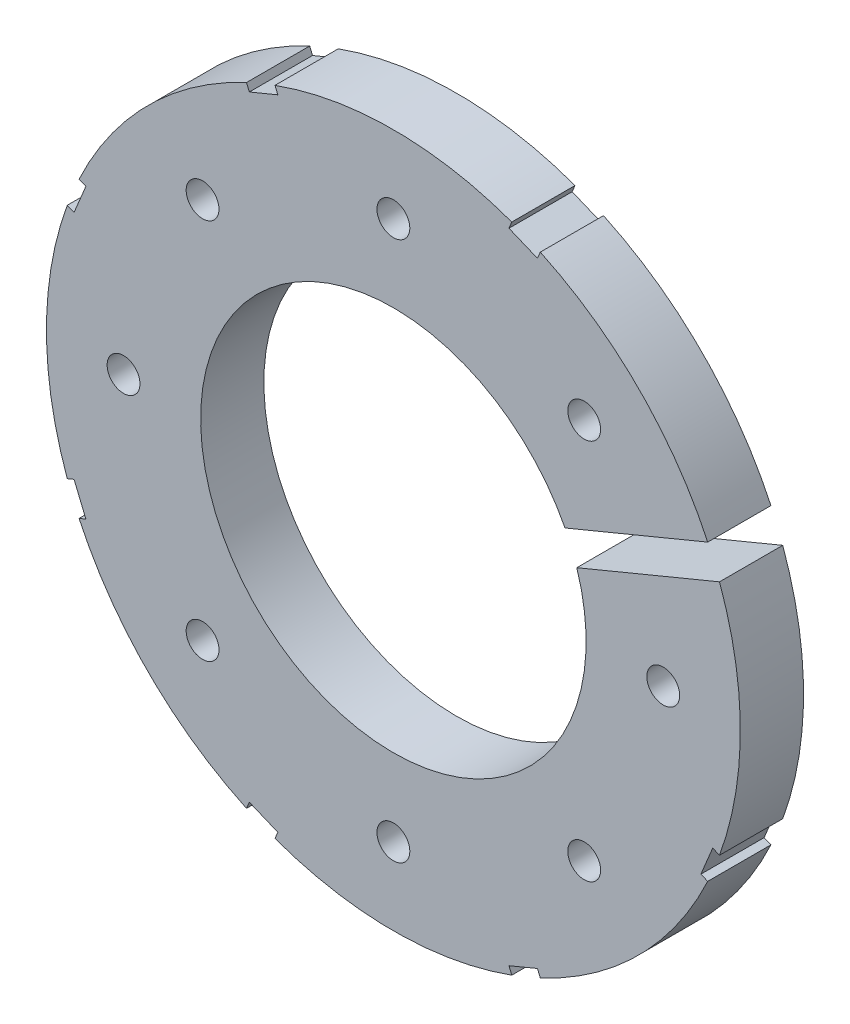
from build123d import *

# Parameters (mm, degrees)
SKETCH4_R             = 28.575
BOSS_EXTRUDE2_DEPTH   = 5.207
SKETCH5_R             = 15.875
CUT_EXTRUDE5_DEPTH    = 6.207
CUT_EXTRUDE11_DEPTH   = 6.207
F_6_32_TAPPED_HOLE1_D = 2.7051


with BuildPart() as part:
    # Sketch4 → Boss-Extrude2 (new body)
    with BuildSketch(Plane.XY):
        Circle(SKETCH4_R)
    extrude(amount=BOSS_EXTRUDE2_DEPTH)

    # Sketch5 → Cut-Extrude5 (cut, through all)
    with BuildSketch(Plane.XY.offset(5.207)):
        Circle(SKETCH5_R)
    extrude(amount=-CUT_EXTRUDE5_DEPTH, mode=Mode.SUBTRACT)

    # Sketch8 → Cut-Extrude11 (cut, through all)
    with BuildSketch(Plane.XY.offset(5.207)):
        Polygon((32.367148217, 14.781549861), (13.593916116, 7.005422516), (14.565932035, 4.658768503), (33.339164135, 12.434895849), align=None)
        Polygon((12.351510066, 26.500513186), (10.004856053, 27.472529104), (9.518848094, 26.299202097), (11.865502107, 25.327186179), align=None)
        Polygon((-10.004856053, 27.472529104), (-12.351510066, 26.500513186), (-11.865502107, 25.327186179), (-9.518848094, 26.299202097), align=None)
        Polygon((-26.500513186, 12.351510066), (-27.472529104, 10.004856053), (-26.299202097, 9.518848094), (-25.327186179, 11.865502107), align=None)
        Polygon((-27.472529104, -10.004856053), (-26.500513186, -12.351510066), (-25.327186179, -11.865502107), (-26.299202097, -9.518848094), align=None)
        Polygon((-12.351510066, -26.500513186), (-10.004856053, -27.472529104), (-9.518848094, -26.299202097), (-11.865502107, -25.327186179), align=None)
        Polygon((10.004856053, -27.472529104), (12.351510066, -26.500513186), (11.865502107, -25.327186179), (9.518848094, -26.299202097), align=None)
        Polygon((26.500513186, -12.351510066), (27.472529104, -10.004856053), (26.299202097, -9.518848094), (25.327186179, -11.865502107), align=None)
    extrude(amount=-CUT_EXTRUDE11_DEPTH, mode=Mode.SUBTRACT)

    # #6-32 Tapped Hole1 (through all)
    with Locations(Plane.XY.offset(5.207)):
        with Locations((22.225, 0), (15.715448212, -15.715448212), (0, -22.225), (-15.715448212, -15.715448212), (-22.225, 0), (-15.715448212, 15.715448212), (0, 22.225), (15.715448212, 15.715448212)):
            Hole(F_6_32_TAPPED_HOLE1_D / 2)


solid = part.part
